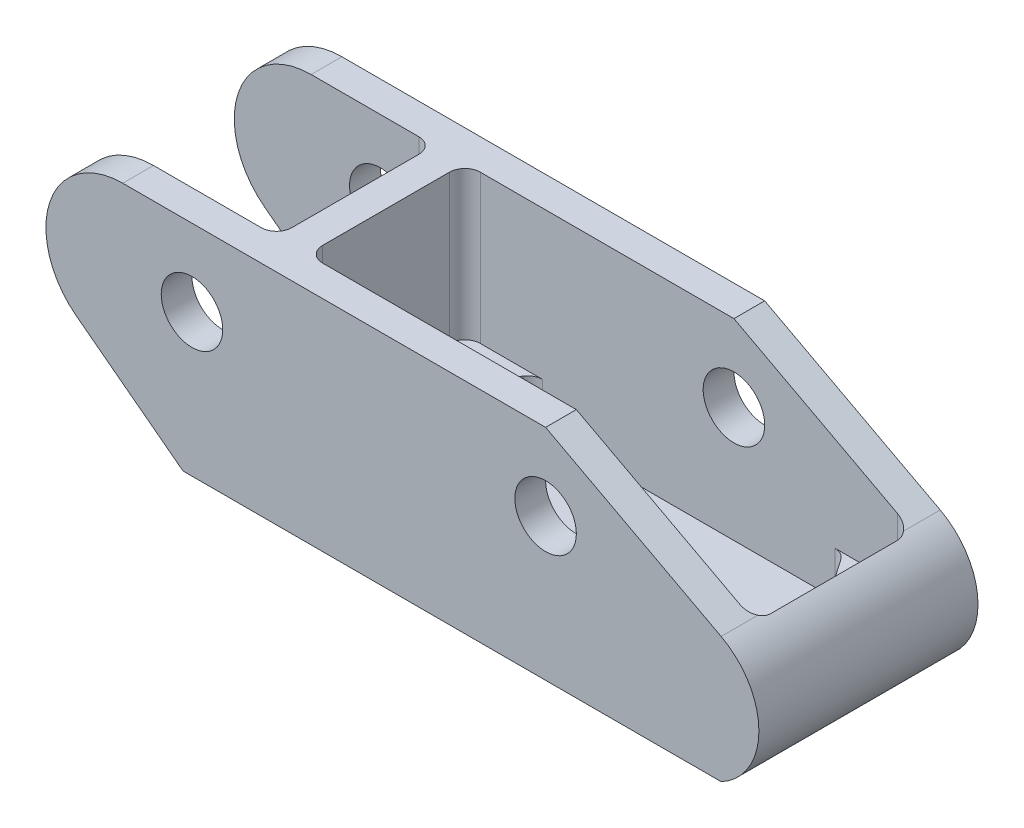
from build123d import *

# Parameters (mm, degrees)
SKETCH1_R           = 4
BOSS_EXTRUDE1_DEPTH = 14.25
SKETCH3_W           = 10
SKETCH3_H           = 20.5
CUT_EXTRUDE1_DEPTH  = 25
CUT_EXTRUDE2_DEPTH  = 19.3
CUT_EXTRUDE3_DEPTH  = 5.7
SKETCH7_R           = 3
CUT_EXTRUDE4_DEPTH  = 4.5000001


with BuildPart() as part:
    # Sketch1 → Boss-Extrude1 (new body, symmetric)
    with BuildSketch(Plane.XY):
        with BuildLine():
            Line((-35, 0), (35, 0))
            ThreePointArc((35, 0), (39.914888853, 8.179748676), (35, 16.359497352))
            Line((35, 16.359497352), (12.167035368, 28.5))
            Line((12.167035368, 28.5), (-42.832964632, 28.5))
            ThreePointArc((-42.832964632, 28.5), (-52.310648732, 21.689593093), (-48.878955781, 10.53470082))
            Line((-48.878955781, 10.53470082), (-35, 0))
        make_face()
        with Locations((12.167035368, 18.5)):
            Circle(SKETCH1_R, mode=Mode.SUBTRACT)
        with Locations((-33.832964632, 18.5)):
            Circle(SKETCH1_R, mode=Mode.SUBTRACT)
    extrude(amount=BOSS_EXTRUDE1_DEPTH, both=True)

    # Sketch3 → Cut-Extrude1 (cut)
    with BuildSketch(Plane(origin=(0, 28.5, 0), x_dir=(1, 0, 0), z_dir=(0, 1, 0))):
        with BuildLine():
            Line((-28.832964632, 10.25), (-42.832964632, 10.25))
            Line((-42.832964632, 10.25), (-42.832964632, -10.25))
            Line((-42.832964632, -10.25), (-28.832964632, -10.25))
            ThreePointArc((-28.832964632, -10.25), (-27.41875107, -9.664213562), (-26.832964632, -8.25))
            Line((-26.832964632, -8.25), (-26.832964632, 8.25))
            ThreePointArc((-26.832964632, 8.25), (-27.41875107, 9.664213562), (-28.832964632, 10.25))
        make_face()
        with Locations((-47.832964632, 0)):
            Rectangle(SKETCH3_W, SKETCH3_H)
    extrude(amount=-CUT_EXTRUDE1_DEPTH, mode=Mode.SUBTRACT)

    # Sketch3_3 → Cut-Extrude2 (cut)
    with BuildSketch(Plane(origin=(0, 28.5, 0), x_dir=(1, 0, 0), z_dir=(0, 1, 0))):
        with BuildLine():
            Line((-20.832964632, 10.25), (33.414888853, 10.25))
            ThreePointArc((33.414888853, 10.25), (34.829102415, 9.664213562), (35.414888853, 8.25))
            Line((35.414888853, 8.25), (35.414888853, -8.25))
            ThreePointArc((35.414888853, -8.25), (34.829102415, -9.664213562), (33.414888853, -10.25))
            Line((33.414888853, -10.25), (-20.832964632, -10.25))
            ThreePointArc((-20.832964632, -10.25), (-22.247178195, -9.664213562), (-22.832964632, -8.25))
            Line((-22.832964632, -8.25), (-22.832964632, 8.25))
            ThreePointArc((-22.832964632, 8.25), (-22.247178195, 9.664213562), (-20.832964632, 10.25))
        make_face()
    extrude(amount=-CUT_EXTRUDE2_DEPTH, mode=Mode.SUBTRACT)

    # Sketch6 → Cut-Extrude3 (cut)
    with BuildSketch(Plane(origin=(0, 9.2, 0), x_dir=(1, 0, 0), z_dir=(0, 1, 0))):
        with BuildLine():
            Line((-18.48327062, 3.406663741), (-14.359422457, 9.38555458))
            ThreePointArc((-14.359422457, 9.38555458), (-13.64281361, 10.020749723), (-12.71305804, 10.25))
            Line((-12.71305804, 10.25), (25.29498226, 10.25))
            ThreePointArc((25.29498226, 10.25), (26.22473783, 10.020749723), (26.941346678, 9.38555458))
            Line((26.941346678, 9.38555458), (31.06519484, 3.406663741))
            ThreePointArc((31.06519484, 3.406663741), (32.126101588, 0), (31.06519484, -3.406663741))
            Line((31.06519484, -3.406663741), (26.941346678, -9.38555458))
            ThreePointArc((26.941346678, -9.38555458), (26.22473783, -10.020749723), (25.29498226, -10.25))
            Line((25.29498226, -10.25), (-12.71305804, -10.25))
            ThreePointArc((-12.71305804, -10.25), (-13.64281361, -10.020749723), (-14.359422457, -9.38555458))
            Line((-14.359422457, -9.38555458), (-18.48327062, -3.406663741))
            ThreePointArc((-18.48327062, -3.406663741), (-19.544177367, 0), (-18.48327062, 3.406663741))
        make_face()
    extrude(amount=-CUT_EXTRUDE3_DEPTH, mode=Mode.SUBTRACT)

    # Sketch7 → Cut-Extrude4 (cut, through all)
    with BuildSketch(Plane(origin=(0, 3.5, 0), x_dir=(1, 0, 0), z_dir=(0, 1, 0))):
        with Locations((26.714888853, 0)):
            Circle(SKETCH7_R)
        with Locations((-13.285111147, 0)):
            Circle(SKETCH7_R)
    extrude(amount=-CUT_EXTRUDE4_DEPTH, mode=Mode.SUBTRACT)


solid = part.part
